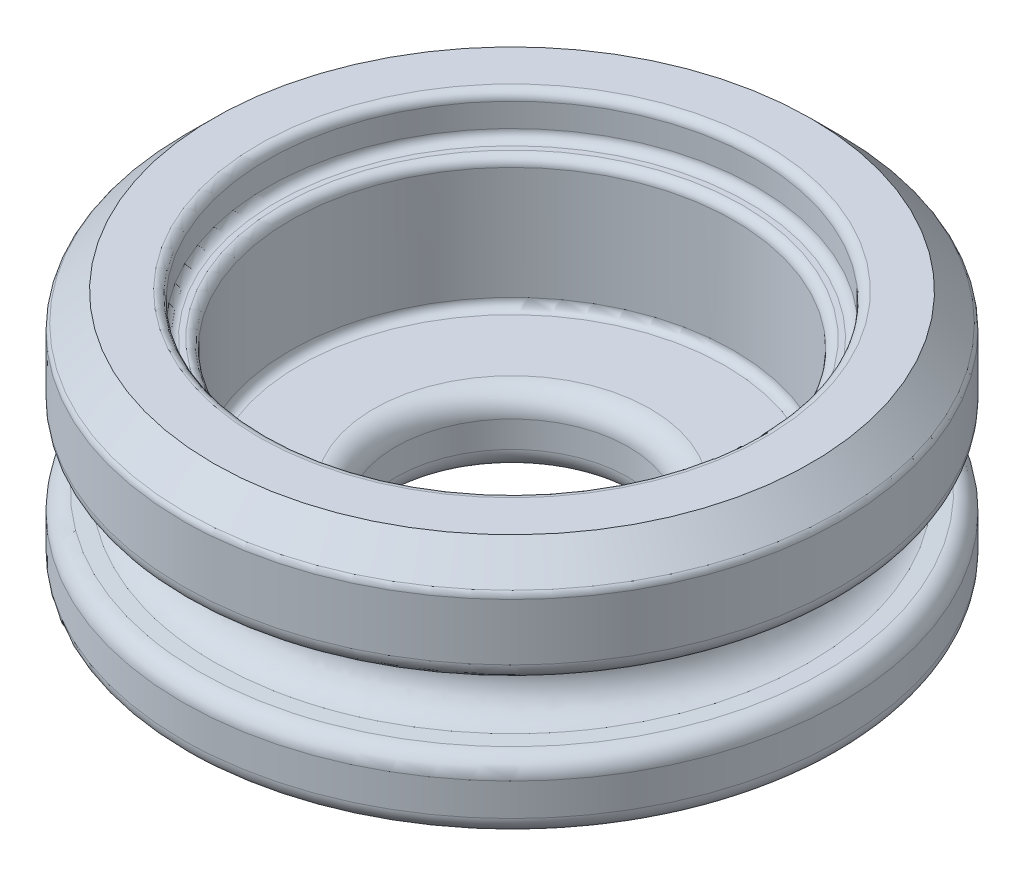
from build123d import *

# Parameters (mm, degrees)
SKETCH2_R           = 9.525
BOSS_EXTRUDE1_DEPTH = 6.985
SKETCH3_R           = 6.4135
CUT_EXTRUDE1_DEPTH  = 6.985
SKETCH4_R           = 7.0723125
CUT_EXTRUDE2_DEPTH  = 1.190625
SKETCH6_R           = 6.4135
SKETCH6_R_2         = 3.3655
BOSS_EXTRUDE2_DEPTH = 2.032
FILLET1_R           = 0.254
FILLET2_R           = 0.508
CHAMFER1_SIZE       = 0.889
FILLET3_R           = 0.254
FILLET4_R           = 0.635
FILLET5_R           = 0.254


with BuildPart() as part:
    # Sketch2 → Boss-Extrude1 (new body)
    with BuildSketch(Plane(origin=(0, 0, 0), x_dir=(1, 0, 0), z_dir=(0, 1, 0))):
        with Locations(Location((0, 0, 0), (0, 0, 270))):
            Circle(SKETCH2_R)
    extrude(amount=BOSS_EXTRUDE1_DEPTH)

    # Sketch3 → Cut-Extrude1 (cut)
    with BuildSketch(Plane(origin=(0, 6.985, 0), x_dir=(1, 0, 0), z_dir=(0, 1, 0))):
        with Locations(Location((0, 0, 0), (0, 0, 270))):
            Circle(SKETCH3_R)
    extrude(amount=-CUT_EXTRUDE1_DEPTH, mode=Mode.SUBTRACT)

    # Sketch4 → Cut-Extrude2 (cut)
    with BuildSketch(Plane(origin=(0, 6.985, 0), x_dir=(1, 0, 0), z_dir=(0, 1, 0))):
        with Locations(Location((0, 0, 0), (0, 0, 270))):
            Circle(SKETCH4_R)
    extrude(amount=-CUT_EXTRUDE2_DEPTH, mode=Mode.SUBTRACT)

    # Cut-Sweep1: sweep along a path in Sketch5
    with BuildLine(Plane(origin=(0, 2.8971875, 0), x_dir=(1, 0, 0), z_dir=(0, 1, 0))) as cut_sweep1_path:
        CenterArc((0, 0), 9.525, 0, 360)
    # 3DSketch1 → Cut-Sweep1 (sweep, cut)
    with BuildSketch(Plane(origin=(0.760529971, 3.841606671, 8.542101645), x_dir=(0, -0.8936668969436978, 0.4487309631694945), z_dir=(-1, 0, 0))):
        with BuildLine():
            Line((0, 0), (0.420188973, 0.854832485))
            Line((0.420188973, 0.854832485), (2.122624412, 0))
            Line((2.122624412, 0), (1.680603435, -0.843870127))
            ThreePointArc((1.680603435, -0.843870127), (0.481116307, -1.137268165), (0, 0))
        make_face()
    sweep(path=cut_sweep1_path.line, mode=Mode.SUBTRACT)

    # Sketch6 → Boss-Extrude2 (add)
    with BuildSketch(Plane.XZ):
        with Locations(Location((0, 0, 0), (0, 0, 90))):
            Circle(SKETCH6_R)
        with Locations(Location((0, 0, 0), (0, 0, 270))):
            Circle(SKETCH6_R_2, mode=Mode.SUBTRACT)
    extrude(amount=-BOSS_EXTRUDE2_DEPTH)

    # Fillet1
    fillet1_edges = [part.edges().sort_by_distance(p)[0] for p in [
        (0, 6.985, -7.0723125),
        (0, 5.794375, -7.0723125),
        (0, 5.794375, -6.4135),
    ]]
    fillet(fillet1_edges, radius=FILLET1_R)

    # Fillet2
    fillet2_edges = [part.edges().sort_by_distance(p)[0] for p in [
        (6.735192091, 3.8496875, 6.735192091),
        (6.735192091, 1.9446875, 6.735192091),
        (0, 0, -9.525),
    ]]
    fillet(fillet2_edges, radius=FILLET2_R)

    # Chamfer1
    chamfer1_edges = [part.edges().sort_by_distance(p)[0] for p in [
        (0, 6.985, -9.525),
    ]]
    chamfer(chamfer1_edges, length=CHAMFER1_SIZE)

    # Fillet3
    fillet3_edges = [part.edges().sort_by_distance(p)[0] for p in [
        (0, 6.096, -9.525),
    ]]
    fillet(fillet3_edges, radius=FILLET3_R)

    # Fillet4
    fillet4_edges = [part.edges().sort_by_distance(p)[0] for p in [
        (0, 2.032, 3.3655),
        (0, 0, 3.3655),
    ]]
    fillet(fillet4_edges, radius=FILLET4_R)

    # Fillet5
    fillet5_edges = [part.edges().sort_by_distance(p)[0] for p in [
        (0, 2.032, -6.4135),
    ]]
    fillet(fillet5_edges, radius=FILLET5_R)


solid = part.part
